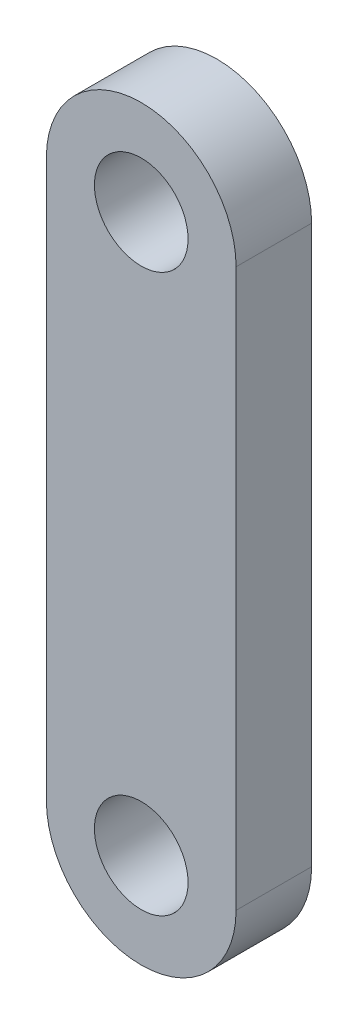
from build123d import *

# Parameters (mm, degrees)
SKETCH1_R           = 3.937
BOSS_EXTRUDE1_DEPTH = 6.35


with BuildPart() as part:
    # Sketch1 → Boss-Extrude1 (new body)
    with BuildSketch(Plane.XY):
        with BuildLine():
            Line((7.9756, 33.503002032), (7.9756, -13.359997968))
            ThreePointArc((7.9756, -13.359997968), (0, -21.335597968), (-7.9756, -13.359997968))
            Line((-7.9756, -13.359997968), (-7.9756, 33.503002032))
            ThreePointArc((-7.9756, 33.503002032), (0, 41.478602032), (7.9756, 33.503002032))
        make_face()
        with Locations((0, 33.503002032)):
            Circle(SKETCH1_R, mode=Mode.SUBTRACT)
        with Locations((0, -13.359997968)):
            Circle(SKETCH1_R, mode=Mode.SUBTRACT)
    extrude(amount=BOSS_EXTRUDE1_DEPTH)


solid = part.part
